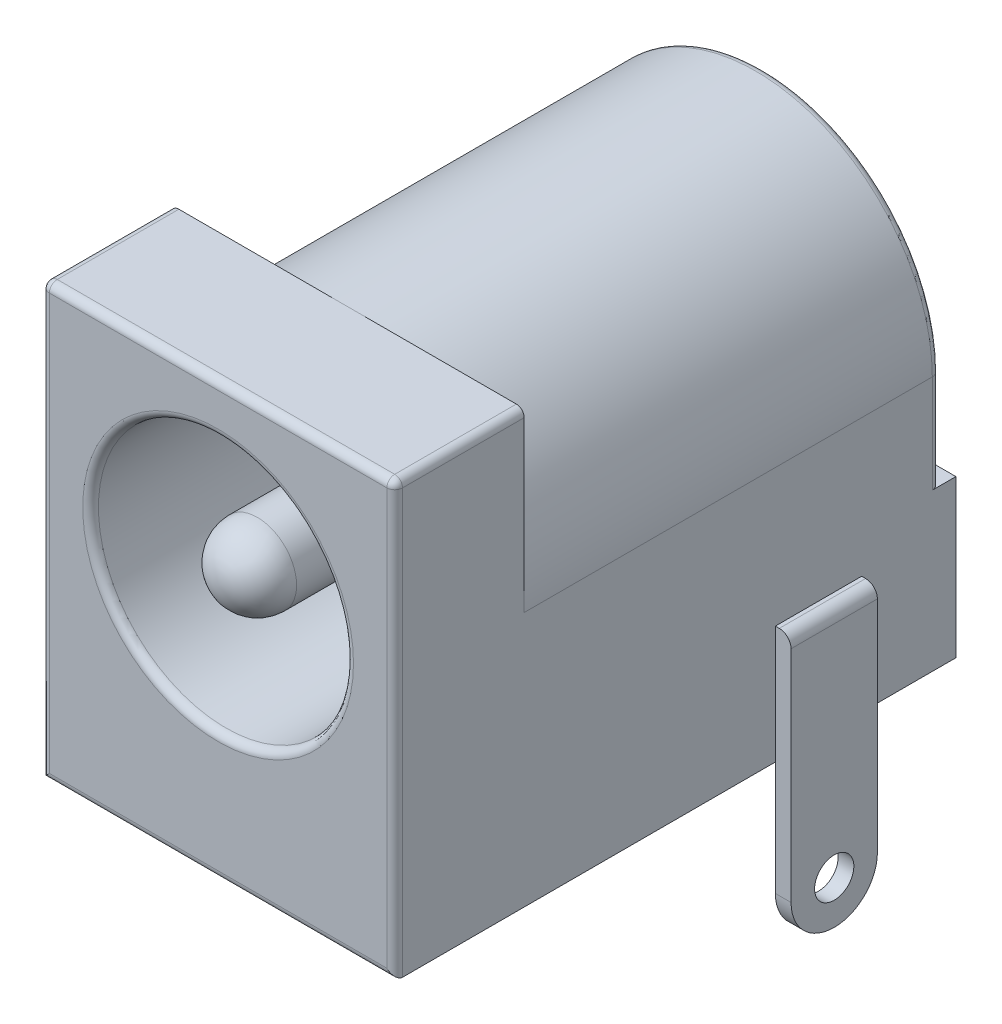
from build123d import *

# Parameters (mm, degrees)
SKETCH1_W           = 9
SKETCH1_H           = 11
BOSS_EXTRUDE1_DEPTH = 3.3
BOSS_EXTRUDE2_DEPTH = 11
SKETCH3_R           = 3.25
CUT_EXTRUDE1_DEPTH  = 11
SKETCH4_R           = 1
BOSS_EXTRUDE3_DEPTH = 11
FILLET1_R           = 1
FILLET2_R           = 0.2
CUT_EXTRUDE2_DEPTH  = 0.4
SKETCH6_R           = 0.5
BOSS_EXTRUDE4_DEPTH = 0.4
SKETCH7_R           = 1.9
SKETCH7_R_2         = 0.5
BOSS_EXTRUDE5_DEPTH = 0.4
SKETCH8_R           = 0.5
BOSS_EXTRUDE6_DEPTH = 0.4
SKETCH9_R           = 0.5
BOSS_EXTRUDE7_DEPTH = 0.4
SKETCH10_W          = 2.8
SKETCH10_H          = 1
BOSS_EXTRUDE8_DEPTH = 6.4
FILLET3_R           = 0.3
FILLET4_R           = 0.2


with BuildPart() as part:
    # Sketch1 → Boss-Extrude1 (new body)
    with BuildSketch(Plane.XY):
        Rectangle(SKETCH1_W, SKETCH1_H)
    extrude(amount=-BOSS_EXTRUDE1_DEPTH)

    # Sketch2 → Boss-Extrude2 (add)
    with BuildSketch(Plane(origin=(0, 0, -3.3), x_dir=(-1, 0, 0), z_dir=(0, 0, -1))):
        with BuildLine():
            Line((-4.5, -5.5), (4.5, -5.5))
            Line((4.5, -5.5), (4.5, 1))
            ThreePointArc((4.5, 1), (0, 5.5), (-4.5, 1))
            Line((-4.5, 1), (-4.5, -5.5))
        make_face()
    extrude(amount=BOSS_EXTRUDE2_DEPTH)

    # Sketch3 → Cut-Extrude1 (cut)
    with BuildSketch(Plane.XY):
        with Locations((0, 1)):
            Circle(SKETCH3_R)
    extrude(amount=-CUT_EXTRUDE1_DEPTH, mode=Mode.SUBTRACT)

    # Sketch4 → Boss-Extrude3 (add)
    with BuildSketch(Plane.XY.offset(-11)):
        with Locations((0, 1)):
            Circle(SKETCH4_R)
    extrude(amount=BOSS_EXTRUDE3_DEPTH)

    # Fillet1
    fillet1_edges = [part.edges().sort_by_distance(p)[0] for p in [
        (-1, 1, 0),
    ]]
    fillet(fillet1_edges, radius=FILLET1_R)

    # Fillet2
    fillet2_edges = [part.edges().sort_by_distance(p)[0] for p in [
        (-3.25, 1, 0),
        (0, -5.5, 0),
        (-4.5, 0, 0),
        (0, 5.5, 0),
        (4.5, 0, 0),
        (-4.5, 5.5, -1.65),
        (4.5, 5.5, -1.65),
    ]]
    fillet(fillet2_edges, radius=FILLET2_R)

    # Sketch5 → Cut-Extrude2 (cut)
    with BuildSketch(Plane(origin=(0, 0, -14.3), x_dir=(-1, 0, 0), z_dir=(0, 0, -1))):
        Polygon((4.5, -1.5), (1.2, -1.5), (1.2, -5.5), (-1.2, -5.5), (-1.2, -1.5), (-4.5, -1.5), (-4.5, 5.5), (4.5, 5.5), align=None)
    extrude(amount=-CUT_EXTRUDE2_DEPTH, mode=Mode.SUBTRACT)

    # Sketch6 → Boss-Extrude4 (add)
    with BuildSketch(Plane(origin=(0, 0, -13.9), x_dir=(-1, 0, 0), z_dir=(0, 0, -1))):
        with BuildLine():
            Line((-1.1, -8.4), (-1.1, 1))
            ThreePointArc((-1.1, 1), (0, 2.1), (1.1, 1))
            Line((1.1, 1), (1.1, -8.4))
            ThreePointArc((1.1, -8.4), (0, -9.5), (-1.1, -8.4))
        make_face()
        with Locations((0, -8.4)):
            Circle(SKETCH6_R, mode=Mode.SUBTRACT)
        with Locations((0, 1)):
            Circle(SKETCH6_R, mode=Mode.SUBTRACT)
    extrude(amount=BOSS_EXTRUDE4_DEPTH)

    # Sketch7 → Boss-Extrude5 (add)
    with BuildSketch(Plane(origin=(0, 0, -14.3), x_dir=(-1, 0, 0), z_dir=(0, 0, -1))):
        with Locations((0, 1)):
            Circle(SKETCH7_R)
        with Locations((0, 1)):
            Circle(SKETCH7_R_2, mode=Mode.SUBTRACT)
    extrude(amount=-BOSS_EXTRUDE5_DEPTH)

    # Sketch8 → Boss-Extrude6 (add)
    with BuildSketch(Plane(origin=(0, 0, -8.1), x_dir=(-1, 0, 0), z_dir=(0, 0, -1))):
        with BuildLine():
            Line((-1.1, -5.145239298), (-1.1, -8.4))
            ThreePointArc((-1.1, -8.4), (0, -9.5), (1.1, -8.4))
            Line((1.1, -8.4), (1.1, -5.145239298))
            Line((1.1, -5.145239298), (-1.1, -5.145239298))
        make_face()
        with Locations((0, -8.4)):
            Circle(SKETCH8_R, mode=Mode.SUBTRACT)
    extrude(amount=-BOSS_EXTRUDE6_DEPTH)

    # Sketch9 → Boss-Extrude7 (add)
    with BuildSketch(Plane(origin=(4.5, 0, 0), x_dir=(0, 0, -1), z_dir=(1, 0, 0))):
        with BuildLine():
            Line((9.7, -2.5), (9.7, -8.4))
            ThreePointArc((9.7, -8.4), (10.8, -9.5), (11.9, -8.4))
            Line((11.9, -8.4), (11.9, -2.5))
            Line((11.9, -2.5), (9.7, -2.5))
        make_face()
        with Locations((10.8, -8.4)):
            Circle(SKETCH9_R, mode=Mode.SUBTRACT)
    extrude(amount=BOSS_EXTRUDE7_DEPTH)

    # Sketch10 → Boss-Extrude8 (add)
    with BuildSketch(Plane.XY.offset(-11)):
        with Locations((0, -2.25)):
            Rectangle(SKETCH10_W, SKETCH10_H)
    extrude(amount=BOSS_EXTRUDE8_DEPTH)

    # Fillet3
    fillet3_edges = [part.edges().sort_by_distance(p)[0] for p in [
        (4.9, -2.5, -10.8),
        (0, -1.75, -4.6),
    ]]
    fillet(fillet3_edges, radius=FILLET3_R)

    # Fillet4
    fillet4_edges = [part.edges().sort_by_distance(p)[0] for p in [
        (0, 5.5, -13.9),
        (4.5, -0.25, -13.9),
        (-4.5, -0.25, -13.9),
    ]]
    fillet(fillet4_edges, radius=FILLET4_R)


solid = part.part
